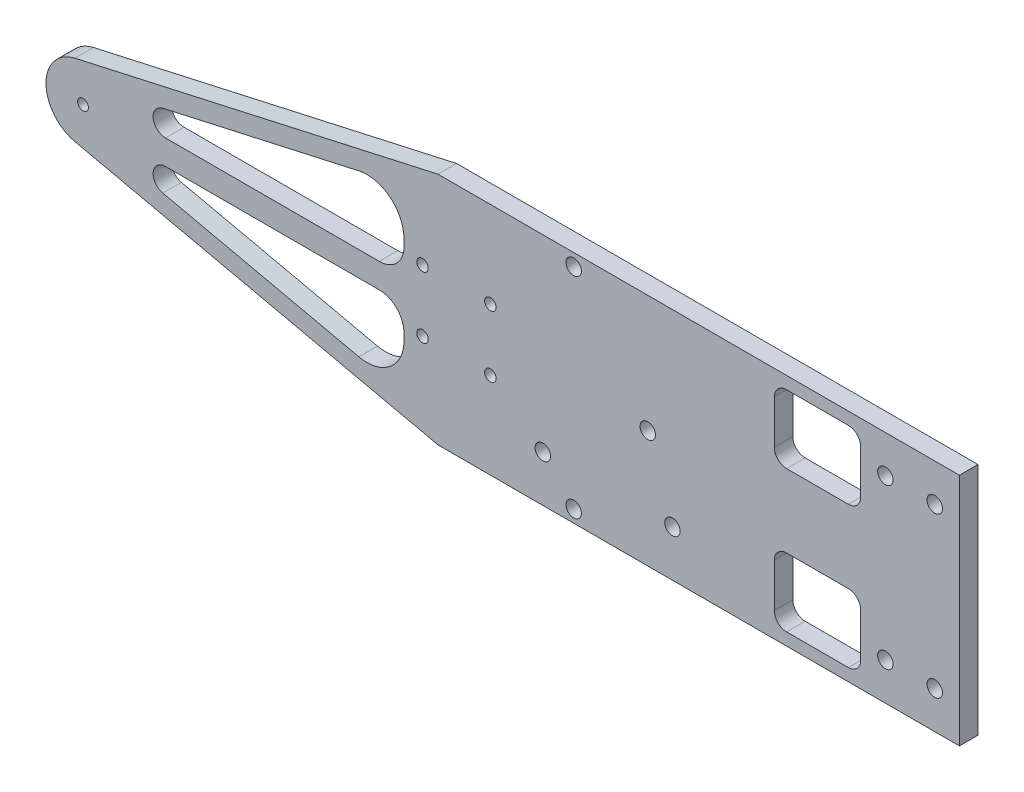
from build123d import *

# Parameters (mm, degrees)
SKETCH1_R          = 1.3890625
SKETCH1_R_2        = 1.984375
EXTRUDE1_DEPTH     = 4.7752
SKETCH9_R          = 1.4732
SKETCH9_R_2        = 1.984375
CUT_EXTRUDE3_DEPTH = 4.7752


with BuildPart() as part:
    # Sketch1 → Extrude1 (new body)
    with BuildSketch(Plane.XY):
        with BuildLine():
            Line((-23.0124, 30.1498), (111.125, 30.1498))
            Line((111.125, 30.1498), (111.125, -30.1498))
            Line((111.125, -30.1498), (-23.0124, -30.1498))
            Line((-23.0124, -30.1498), (-116.376349272, -9.295934526))
            ThreePointArc((-116.376349272, -9.295934526), (-123.825, 0), (-116.376349272, 9.295934526))
            Line((-116.376349272, 9.295934526), (-23.0124, 30.1498))
        make_face()
        with Locations((-114.3, 0)):
            Circle(SKETCH1_R, mode=Mode.SUBTRACT)
        with Locations((104.775, -20.5105)):
            Circle(SKETCH1_R_2, mode=Mode.SUBTRACT)
        with Locations((92.075, -20.5105)):
            Circle(SKETCH1_R_2, mode=Mode.SUBTRACT)
        with Locations((104.775, 20.5105)):
            Circle(SKETCH1_R_2, mode=Mode.SUBTRACT)
        with Locations((92.075, 20.5105)):
            Circle(SKETCH1_R_2, mode=Mode.SUBTRACT)
        with BuildLine():
            Line((-93.787006647, 9.448644842), (-43.351349272, 20.714003926))
            ThreePointArc((-43.351349272, 20.714003926), (-35.318977914, 18.85119969), (-31.75, 11.4180694))
            Line((-31.75, 11.4180694), (-31.75, 9.525))
            ThreePointArc((-31.75, 9.525), (-33.609871939, 5.034871939), (-38.1, 3.175))
            Line((-38.1, 3.175), (-93.094890223, 3.175))
            ThreePointArc((-93.094890223, 3.175), (-96.250743703, 6.001842258), (-93.787006647, 9.448644842))
        make_face(mode=Mode.SUBTRACT)
        with BuildLine():
            Line((-93.787006647, -9.448644842), (-43.351349272, -20.714003926))
            ThreePointArc((-43.351349272, -20.714003926), (-35.318977914, -18.85119969), (-31.75, -11.4180694))
            Line((-31.75, -11.4180694), (-31.75, -9.525))
            ThreePointArc((-31.75, -9.525), (-33.609871939, -5.034871939), (-38.1, -3.175))
            Line((-38.1, -3.175), (-93.094890223, -3.175))
            ThreePointArc((-93.094890223, -3.175), (-96.250743703, -6.001842258), (-93.787006647, -9.448644842))
        make_face(mode=Mode.SUBTRACT)
        with BuildLine():
            Line((85.725, -23.7998), (85.725, -12.573))
            ThreePointArc((85.725, -12.573), (84.79506403, -10.32793597), (82.55, -9.398))
            Line((82.55, -9.398), (66.675, -9.398))
            ThreePointArc((66.675, -9.398), (64.42993597, -10.32793597), (63.5, -12.573))
            Line((63.5, -12.573), (63.5, -23.7998))
            ThreePointArc((63.5, -23.7998), (64.42993597, -26.04486403), (66.675, -26.9748))
            Line((66.675, -26.9748), (82.55, -26.9748))
            ThreePointArc((82.55, -26.9748), (84.79506403, -26.04486403), (85.725, -23.7998))
        make_face(mode=Mode.SUBTRACT)
        with BuildLine():
            Line((85.725, 23.7998), (85.725, 12.573))
            ThreePointArc((85.725, 12.573), (84.79506403, 10.32793597), (82.55, 9.398))
            Line((82.55, 9.398), (66.675, 9.398))
            ThreePointArc((66.675, 9.398), (64.42993597, 10.32793597), (63.5, 12.573))
            Line((63.5, 12.573), (63.5, 23.7998))
            ThreePointArc((63.5, 23.7998), (64.42993597, 26.04486403), (66.675, 26.9748))
            Line((66.675, 26.9748), (82.55, 26.9748))
            ThreePointArc((82.55, 26.9748), (84.79506403, 26.04486403), (85.725, 23.7998))
        make_face(mode=Mode.SUBTRACT)
    extrude(amount=-EXTRUDE1_DEPTH)

    # Sketch9 → Cut-Extrude3 (cut)
    with BuildSketch(Plane.XY):
        with Locations((-26.9875, 7.9248)):
            Circle(SKETCH9_R)
        with Locations((-9.525, -7.9248)):
            Circle(SKETCH9_R)
        with Locations((-26.9875, -7.9248)):
            Circle(SKETCH9_R)
        with Locations((11.90625, -26.9875)):
            Circle(SKETCH9_R_2)
        with Locations((-9.525, 7.9248)):
            Circle(SKETCH9_R)
        with Locations((11.90625, 26.9875)):
            Circle(SKETCH9_R_2)
        with Locations((30.95625, 0)):
            Circle(SKETCH9_R_2)
        with Locations((3.96875, -18.25625)):
            Circle(SKETCH9_R_2)
        with Locations((37.30625, -18.25625)):
            Circle(SKETCH9_R_2)
    extrude(amount=-CUT_EXTRUDE3_DEPTH, mode=Mode.SUBTRACT)


solid = part.part
